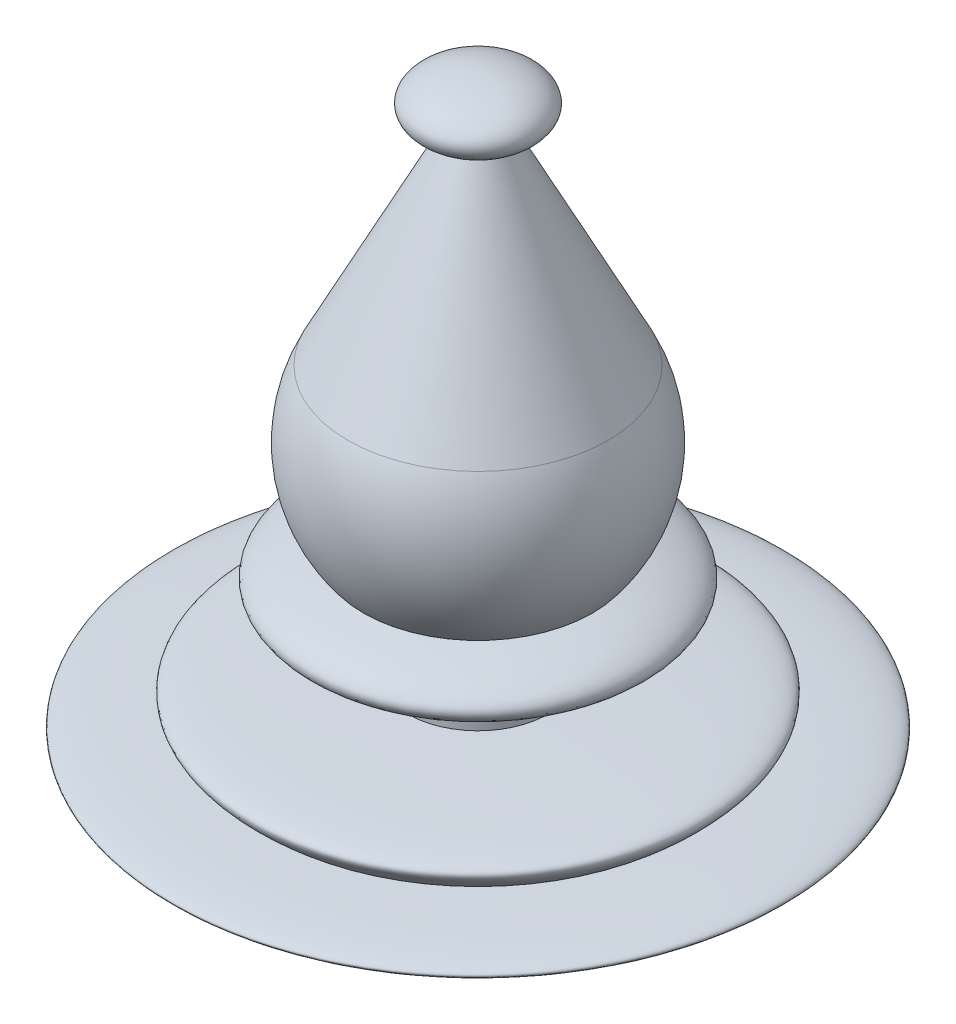
from build123d import *


with BuildPart() as part:
    # Sketch1 → Revolve1 (revolve)
    with BuildSketch(Plane.XY):
        with BuildLine():
            Line((6, -13), (6, -12.802149321))
            add(Edge.make_bspline(
                [(6, -12.802149321), (25.63222609, -10.871888654), (9.754562306, -7.73374733)],
                knots=[5.14256284, 5.14256284, 5.14256284, 7.10895832, 7.10895832, 7.10895832], degree=2, weights=[1, 0.554363988, 1]))
            ThreePointArc((9.754562306, -7.73374733), (12.387779837, -1.226883967), (11.082076421, 5.670089572))
            Line((11.082076421, 5.670089572), (2.229172504, 22.972912837))
            add(Edge.make_bspline(
                [(2.229172504, 22.972912837), (5.801776121, 23.768487815), (4.893946262, 25.515100596), (3.986116403, 27.261713378), (0, 27.261713378)],
                knots=[5.171917438, 5.171917438, 5.171917438, 6.512949536, 6.512949536, 7.853981634, 7.853981634, 7.853981634], degree=2, weights=[1, 0.783501102, 1, 0.783501102, 1]))
            Line((0, 27.261713378), (0, -24.552854996))
            add(Edge.make_bspline(
                [(0, -24.552854996), (64.571341351, -20.768140469), (18, -20.049402031)],
                knots=[4.707858797, 4.707858797, 4.707858797, 7.084243836, 7.084243836, 7.084243836], degree=2, weights=[1, 0.373337273, 1]))
            add(Edge.make_bspline(
                [(6, -17.049402031), (20.916006981, -17.512739159), (18, -20.049402031)],
                knots=[0, 0, 0, 1, 1, 1], degree=2, weights=[1, 2.720100719, 1]))
            Line((6, -17.049402031), (6, -13))
        make_face()
    revolve(axis=Axis((0, 27.261713378, 0), (0, -1, 0)))


solid = part.part
